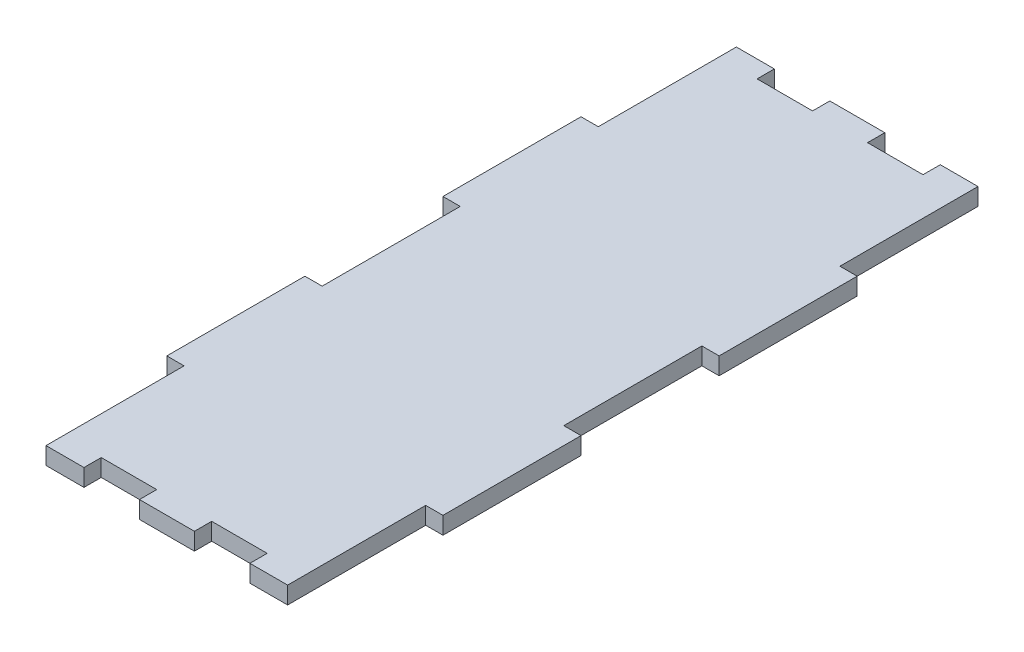
from build123d import *

# Parameters (mm, degrees)
SKETCH1_W                 = 50.8
SKETCH1_H                 = 127
BOSS_EXTRUDE1_DEPTH       = 3.175
SKETCH2_W                 = 3.175
SKETCH2_H                 = 25.4
CUT_EXTRUDE1_DEPTH        = 3.175
LPATTERN1_COUNT           = 2
LPATTERN1_PITCH           = 50.8
LPATTERN2_COUNT           = 2
LPATTERN2_PITCH           = 50.8
SKETCH3_W                 = 3.175
SKETCH3_H                 = 25.4
CUT_EXTRUDE2_DEPTH        = 3.175
LPATTERN3_COUNT           = 2
LPATTERN3_PITCH           = 50.8
LPATTERN4_COPY_1_SKETCH_W = 3.175
LPATTERN4_COPY_1_SKETCH_H = 25.4
LPATTERN4_COPY_1_DEPTH    = 3.175
LPATTERN4_COPY_2_SKETCH_W = 3.175
LPATTERN4_COPY_2_SKETCH_H = 25.4
LPATTERN4_COPY_2_DEPTH    = 3.175
SKETCH6_W                 = 10.205647586
SKETCH6_H                 = 3.175
CUT_EXTRUDE3_DEPTH        = 3.175
LPATTERN5_COUNT           = 2
LPATTERN5_PITCH           = 20.32


with BuildPart() as part:
    # Sketch1 → Boss-Extrude1 (new body)
    with BuildSketch(Plane(origin=(0, 0, 0), x_dir=(1, 0, 0), z_dir=(0, 1, 0))):
        Rectangle(SKETCH1_W, SKETCH1_H)
    extrude(amount=BOSS_EXTRUDE1_DEPTH)

    # Sketch2 → Cut-Extrude1 (cut)
    with BuildSketch(Plane(origin=(0, 3.175, 0), x_dir=(1, 0, 0), z_dir=(0, 1, 0))):
        with Locations((-23.8125, 0)):
            Rectangle(SKETCH2_W, SKETCH2_H)
    cut_extrude1 = extrude(amount=-CUT_EXTRUDE1_DEPTH, mode=Mode.SUBTRACT)

    # LPattern1: Cut-Extrude1 ×2
    with Locations(*[(0, 0, -i * LPATTERN1_PITCH) for i in range(1, LPATTERN1_COUNT)]):
        add(cut_extrude1, mode=Mode.SUBTRACT)

    # LPattern2: Cut-Extrude1 ×2
    with Locations(*[(0, 0, i * LPATTERN2_PITCH) for i in range(1, LPATTERN2_COUNT)]):
        add(cut_extrude1, mode=Mode.SUBTRACT)

    # Sketch3 → Cut-Extrude2 (cut)
    with BuildSketch(Plane(origin=(0, 3.175, 0), x_dir=(1, 0, 0), z_dir=(0, 1, 0))):
        with Locations((23.8125, 50.8)):
            Rectangle(SKETCH3_W, SKETCH3_H)
    cut_extrude2 = extrude(amount=-CUT_EXTRUDE2_DEPTH, mode=Mode.SUBTRACT)

    # LPattern3: Cut-Extrude2 ×2
    with Locations(*[(0, 0, i * LPATTERN3_PITCH) for i in range(1, LPATTERN3_COUNT)]):
        add(cut_extrude2, mode=Mode.SUBTRACT)

    # LPattern4 copy 1 sketch → LPattern4 copy 1 (cut)
    with BuildSketch(Plane(origin=(0, 3.175, 101.6), x_dir=(1, 0, 0), z_dir=(0, 1, 0))):
        with Locations((23.8125, 50.8)):
            Rectangle(LPATTERN4_COPY_1_SKETCH_W, LPATTERN4_COPY_1_SKETCH_H)
    extrude(amount=-LPATTERN4_COPY_1_DEPTH, mode=Mode.SUBTRACT)

    # LPattern4 copy 2 sketch → LPattern4 copy 2 (cut)
    with BuildSketch(Plane(origin=(0, 3.175, 50.8), x_dir=(1, 0, 0), z_dir=(0, 1, 0))):
        with Locations((23.8125, 50.8)):
            Rectangle(LPATTERN4_COPY_2_SKETCH_W, LPATTERN4_COPY_2_SKETCH_H)
    extrude(amount=-LPATTERN4_COPY_2_DEPTH, mode=Mode.SUBTRACT)

    # Sketch6 → Cut-Extrude3 (cut)
    with BuildSketch(Plane(origin=(0, 3.175, 0), x_dir=(1, 0, 0), z_dir=(0, 1, 0))):
        with Locations((10.182823793, 61.9125)):
            Rectangle(SKETCH6_W, SKETCH6_H)
        with Locations((10.182823793, -61.9125)):
            Rectangle(SKETCH6_W, SKETCH6_H)
    cut_extrude3 = extrude(amount=-CUT_EXTRUDE3_DEPTH, mode=Mode.SUBTRACT)

    # LPattern5: Cut-Extrude3 ×2
    with Locations(*[(-i * LPATTERN5_PITCH, 0, 0) for i in range(1, LPATTERN5_COUNT)]):
        add(cut_extrude3, mode=Mode.SUBTRACT)


solid = part.part
